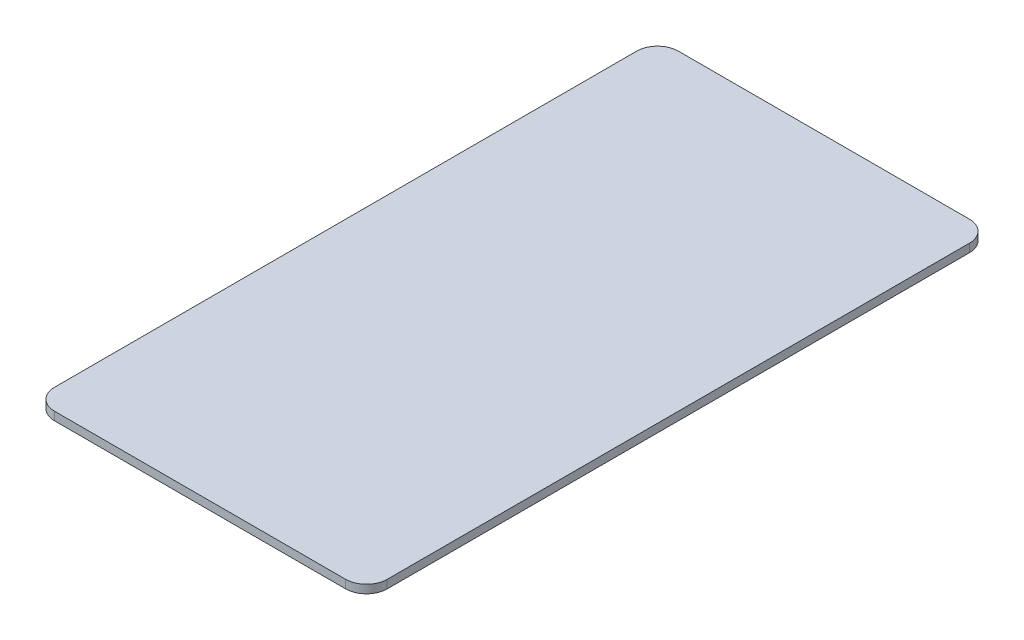
from build123d import *

# Parameters (mm, degrees)
SKETCH1_W           = 50.8
SKETCH1_H           = 95.25
BOSS_EXTRUDE1_DEPTH = 1.27
FILLET1_R           = 3.175


with BuildPart() as part:
    # Sketch1 → Boss-Extrude1 (new body)
    with BuildSketch(Plane(origin=(0, 0, 0), x_dir=(1, 0, 0), z_dir=(0, 1, 0))):
        with Locations((25.4, 47.625)):
            Rectangle(SKETCH1_W, SKETCH1_H)
    extrude(amount=BOSS_EXTRUDE1_DEPTH)

    # Fillet1
    fillet1_edges = [part.edges().sort_by_distance(p)[0] for p in [
        (0, 0.635, -95.25),
        (50.8, 0.635, -95.25),
        (50.8, 0.635, 0),
        (0, 0.635, 0),
    ]]
    fillet(fillet1_edges, radius=FILLET1_R)


solid = part.part
